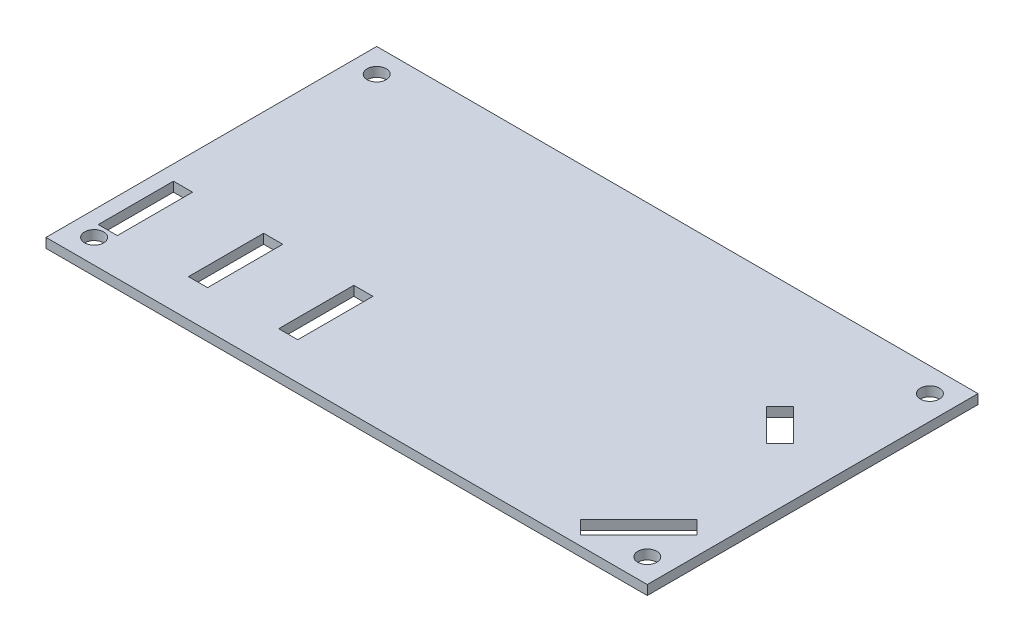
from build123d import *

# Parameters (mm, degrees)
SKETCH1_W           = 200
SKETCH1_H           = 110
BOSS_EXTRUDE1_DEPTH = 3.175
CUT_EXTRUDE1_REACH  = 230.276
CUT_EXTRUDE2_REACH  = 230.276
CUT_EXTRUDE3_REACH  = 230.276
SKETCH4_W           = 6.35
SKETCH4_H           = 25
SKETCH5_R           = 3.175
CUT_EXTRUDE4_DEPTH  = 10
LPATTERN1_COUNT     = 3
LPATTERN1_PITCH     = 30


with BuildPart() as part:
    # Sketch1 → Boss-Extrude1 (new body)
    with BuildSketch(Plane(origin=(0, 0, 0), x_dir=(1, 0, 0), z_dir=(0, 1, 0))):
        with Locations((100, 55)):
            Rectangle(SKETCH1_W, SKETCH1_H)
    extrude(amount=BOSS_EXTRUDE1_DEPTH)

    # Sketch2 → Cut-Extrude1 (cut, up to next)
    with BuildSketch(Plane(origin=(0, 3.175, 0), x_dir=(1, 0, 0), z_dir=(0, 1, 0)), mode=Mode.PRIVATE) as cut_extrude1_sk1:
        Polygon((194, 22.467727943), (174.625274195, 3.093002139), (170.135146135, 7.583130199), (189.509871939, 26.957856004), align=None)
    cut_extrude1_tool1 = extrude(cut_extrude1_sk1.sketch, amount=-CUT_EXTRUDE1_REACH, mode=Mode.PRIVATE) & part.part
    add(cut_extrude1_tool1.solids().sort_by_distance((182.067573, 3.175, -15.025429))[0], mode=Mode.SUBTRACT)

    # Sketch3 → Cut-Extrude2 (cut, up to next)
    with BuildSketch(Plane(origin=(0, 3.175, 0), x_dir=(1, 0, 0), z_dir=(0, 1, 0)), mode=Mode.PRIVATE) as cut_extrude2_sk1:
        Polygon((168.509871939, 71.151828996), (179.151828996, 60.509871939), (183.641957057, 65), (173, 75.641957057), align=None)
    cut_extrude2_tool1 = extrude(cut_extrude2_sk1.sketch, amount=-CUT_EXTRUDE2_REACH, mode=Mode.PRIVATE) & part.part
    add(cut_extrude2_tool1.solids().sort_by_distance((176.075914, 3.175, -68.075914))[0], mode=Mode.SUBTRACT)

    # Sketch4 → Cut-Extrude3 (cut, up to next)
    with BuildSketch(Plane(origin=(0, 3.175, 0), x_dir=(1, 0, 0), z_dir=(0, 1, 0)), mode=Mode.PRIVATE) as cut_extrude3_sk1:
        with Locations((8.175, 24.889181128)):
            Rectangle(SKETCH4_W, SKETCH4_H)
    cut_extrude3_tool1 = extrude(cut_extrude3_sk1.sketch, amount=-CUT_EXTRUDE3_REACH, mode=Mode.PRIVATE) & part.part
    cut_extrude3 = cut_extrude3_tool1.solids().sort_by_distance((8.175, 3.175, -24.889181))[0]
    add(cut_extrude3, mode=Mode.SUBTRACT)

    # Sketch5 → Cut-Extrude4 (cut)
    with BuildSketch(Plane(origin=(0, 3.175, 0), x_dir=(1, 0, 0), z_dir=(0, 1, 0))):
        with Locations((8, 102)):
            Circle(SKETCH5_R)
        with Locations((192, 102)):
            Circle(SKETCH5_R)
        with Locations((192, 8)):
            Circle(SKETCH5_R)
        with Locations((8, 8)):
            Circle(SKETCH5_R)
    extrude(amount=-CUT_EXTRUDE4_DEPTH, mode=Mode.SUBTRACT)

    # LPattern1: Cut-Extrude3 ×3
    with Locations(*[(i * LPATTERN1_PITCH, 0, 0) for i in range(1, LPATTERN1_COUNT)]):
        add(cut_extrude3, mode=Mode.SUBTRACT)


solid = part.part
